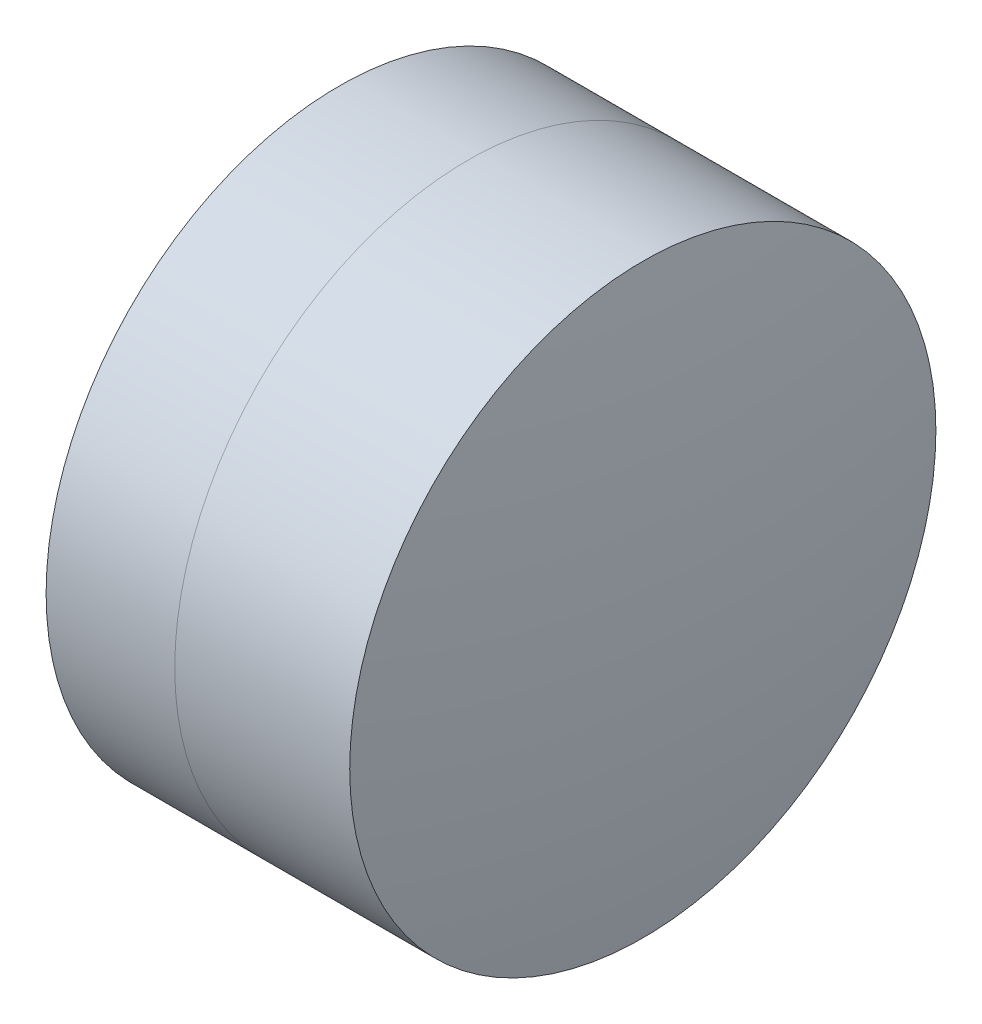
from build123d import *


with BuildPart() as part:
    # 草图1 one side → 旋转1 (revolve)
    with BuildSketch(Plane(origin=(0, 0, 0), x_dir=(1, 0, 0), z_dir=(0, 1, 0)), mode=Mode.PRIVATE) as revolve_1_sk:
        with BuildLine():
            ThreePointArc((6.173100806, 3.15), (5.805962884, 1.593979829), (5.68260434, 0))
            Line((5.68260434, 0), (8.28260434, 0))
            ThreePointArc((8.28260434, 0), (8.098502957, 1.616399754), (7.555629336, 3.15))
            Line((7.555629336, 3.15), (6.173100806, 3.15))
        make_face()
    revolve(revolve_1_sk.sketch.rotate(Axis((-0.816062176, 0, 0), (1, 0, 0)), 180), axis=Axis((-0.816062176, 0, 0), (1, 0, 0)))  # turned: the seam where the file's is


with BuildPart() as body_2:
    # 草图2 one side → 旋转3 (revolve)
    with BuildSketch(Plane(origin=(0, 0, 0), x_dir=(1, 0, 0), z_dir=(0, 1, 0)), mode=Mode.PRIVATE) as revolve_3_sk:
        with BuildLine():
            Line((9.436276432, 3.15), (7.555629336, 3.15))
            ThreePointArc((7.555629336, 3.15), (8.098502957, 1.616399754), (8.28260434, 0))
            Line((8.28260434, 0), (9.68260434, 0))
            ThreePointArc((9.68260434, 0), (9.620928504, 1.57980833), (9.436276432, 3.15))
        make_face()
    revolve(revolve_3_sk.sketch.rotate(Axis((-0.551919993, 0, 0), (1, 0, 0)), 180), axis=Axis((-0.551919993, 0, 0), (1, 0, 0)))  # turned: the seam where the file's is


solid = Compound([part.part, body_2.part])
